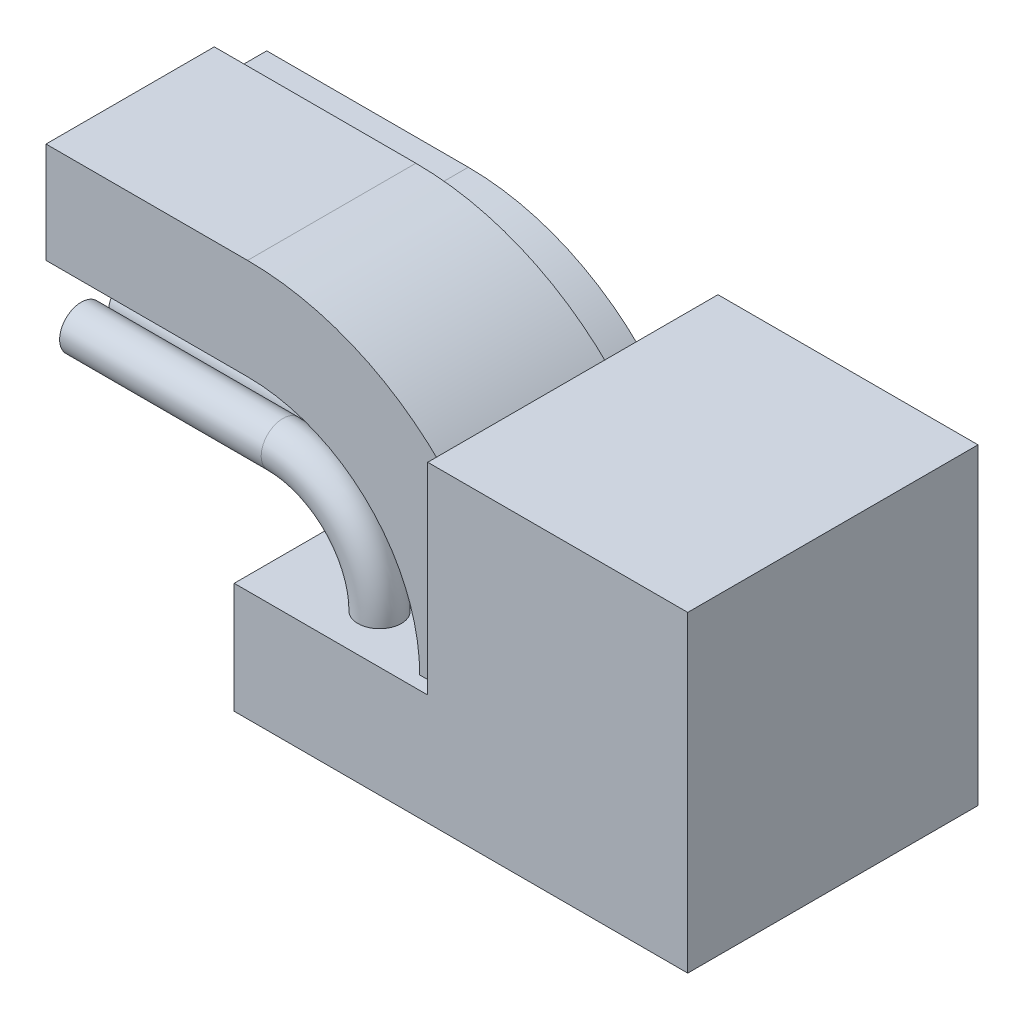
from build123d import *

# Parameters (mm, degrees)
SKETCH1_W           = 57.15
SKETCH1_H           = 36.576
BOSS_EXTRUDE1_DEPTH = 13.97
SKETCH2_W           = 32.766
SKETCH2_H           = 36.576
BOSS_EXTRUDE2_DEPTH = 25.4
SKETCH4_R           = 2.7305
REVOLVE1_ANGLE      = 90
BOSS_EXTRUDE4_DEPTH = 25.4
SKETCH6_R           = 2.7305
BOSS_EXTRUDE5_DEPTH = 25.4
SKETCH7_R           = 2.7305
BOSS_EXTRUDE6_DEPTH = 25.4
SKETCH8_R           = 2.7305
BOSS_EXTRUDE7_DEPTH = 25.4


with BuildPart() as part:
    # Sketch1 → Boss-Extrude1 (new body)
    with BuildSketch(Plane(origin=(0, 0, 0), x_dir=(1, 0, 0), z_dir=(0, 1, 0))):
        Rectangle(SKETCH1_W, SKETCH1_H)
    extrude(amount=BOSS_EXTRUDE1_DEPTH)

    # Sketch2 → Boss-Extrude2 (add)
    with BuildSketch(Plane(origin=(0, 13.97, 0), x_dir=(1, 0, 0), z_dir=(0, 1, 0))):
        with Locations((12.192, 0)):
            Rectangle(SKETCH2_W, SKETCH2_H)
    extrude(amount=BOSS_EXTRUDE2_DEPTH)

    # Sketch4 → Revolve1 (revolve)
    with BuildSketch(Plane(origin=(0, 13.97, 0), x_dir=(1, 0, 0), z_dir=(0, 1, 0))):
        with Locations((-16.383, 0)):
            Circle(SKETCH4_R)
        with Locations((-16.383, -5.999114577)):
            Circle(SKETCH4_R)
        with Locations((-16.383, -12.157013846)):
            Circle(SKETCH4_R)
        Polygon((5.819191805, -16.603614577), (-6.880808195, -16.603614577), (-6.880808195, 4.605385423), (-0.965296127, 4.605385423), (-0.965296127, 11.209385423), (2.082703873, 11.209385423), (2.082703873, 4.605385423), (5.819191805, 4.605385423), align=None)
    revolve(axis=Axis((-28.575, 13.97, 18.288), (0, 0, 1)), revolution_arc=REVOLVE1_ANGLE)

    # Sketch5 → Boss-Extrude4 (add)
    with BuildSketch(Plane(origin=(-28.575, 0, 0), x_dir=(0, -1, 0), z_dir=(-1, 0, 0))):
        Polygon((-44.627703873, -4.605385423), (-48.364191805, -4.605385423), (-48.364191805, 16.603614577), (-35.664191805, 16.603614577), (-35.664191805, -4.605385423), (-41.579703873, -4.605385423), (-41.579703873, -11.209385423), (-44.627703873, -11.209385423), align=None)
    extrude(amount=BOSS_EXTRUDE4_DEPTH)

    # Sketch6 → Boss-Extrude5 (add)
    with BuildSketch(Plane(origin=(-28.575, 0, 0), x_dir=(0, -1, 0), z_dir=(-1, 0, 0))):
        with Locations((-26.162, 0)):
            Circle(SKETCH6_R)
    extrude(amount=BOSS_EXTRUDE5_DEPTH)

    # Sketch7 → Boss-Extrude6 (add)
    with BuildSketch(Plane(origin=(-28.575, 0, 0), x_dir=(0, -1, 0), z_dir=(-1, 0, 0))):
        with Locations((-26.162, 5.999114577)):
            Circle(SKETCH7_R)
    extrude(amount=BOSS_EXTRUDE6_DEPTH)

    # Sketch8 → Boss-Extrude7 (add)
    with BuildSketch(Plane(origin=(-28.575, 0, 0), x_dir=(0, -1, 0), z_dir=(-1, 0, 0))):
        with Locations((-26.162, 12.157013846)):
            Circle(SKETCH8_R)
    extrude(amount=BOSS_EXTRUDE7_DEPTH)


solid = part.part
